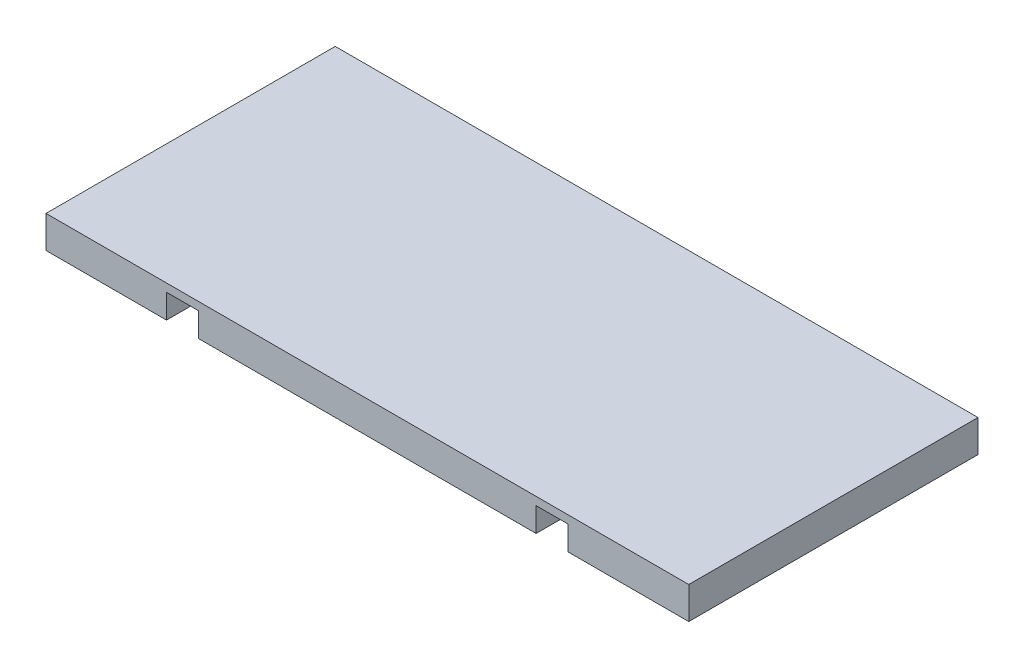
from build123d import *

# Parameters (mm, degrees)
BOSS_EXTRUDE1_DEPTH = 18


with BuildPart() as part:
    # Sketch1 → Boss-Extrude1 (new body)
    with BuildSketch(Plane.XY):
        Polygon((-20, -2), (-12.5, -2), (-12.5, -0.5), (-10.5, -0.5), (-10.5, -2), (10.5, -2), (10.5, -0.5), (12.5, -0.5), (12.5, -2), (20, -2), (20, 0), (-20, 0), align=None)
    extrude(amount=BOSS_EXTRUDE1_DEPTH)


solid = part.part
